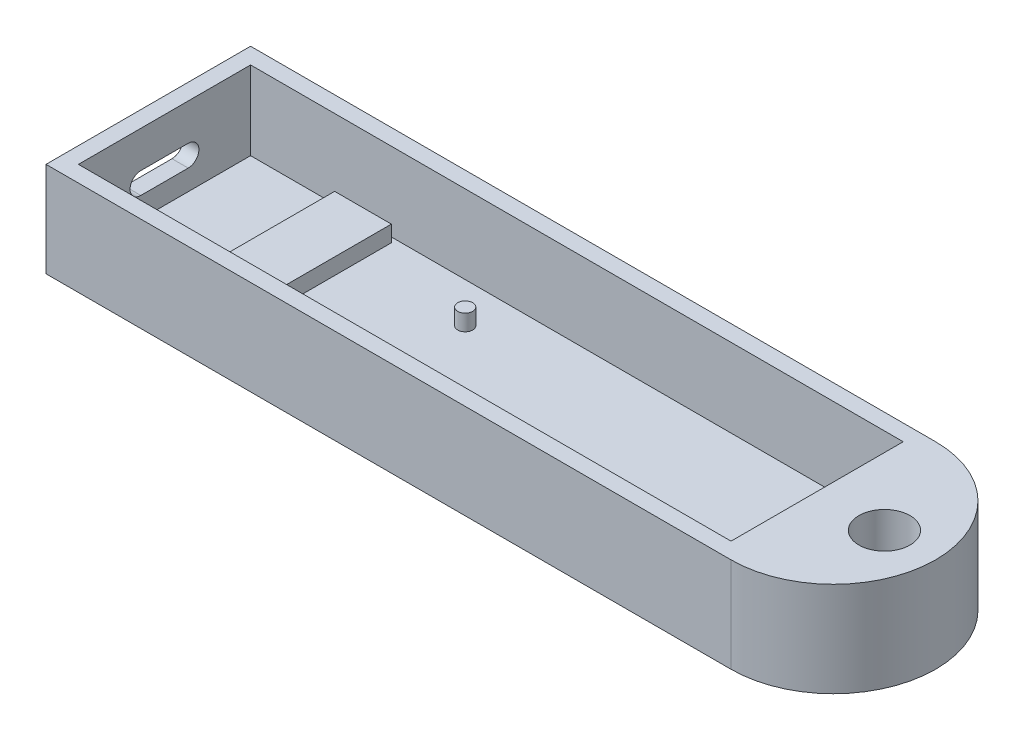
from build123d import *

# Parameters (mm, degrees)
SKETCH1_W           = 7
SKETCH1_H           = 20
BOSS_EXTRUDE2_DEPTH = 4
SKETCH1_4_R         = 0.925
SKETCH1_4_W         = 7
SKETCH1_4_H         = 20
BOSS_EXTRUDE3_DEPTH = 2
SKETCH1_5_R         = 0.925
BOSS_EXTRUDE4_DEPTH = 4
SKETCH1_6_R         = 3.155
BOSS_EXTRUDE5_DEPTH = 11.7
CUT_EXTRUDE1_DEPTH  = 4.85


with BuildPart() as part:
    # Sketch1 → Boss-Extrude2 (new body)
    with BuildSketch(Plane(origin=(0, 0, 0), x_dir=(1, 0, 0), z_dir=(0, 1, 0))):
        with Locations((-33.759922188, -0.124838084)):
            Rectangle(SKETCH1_W, SKETCH1_H)
    extrude(amount=BOSS_EXTRUDE2_DEPTH)

    # Sketch1_4 → Boss-Extrude3 (add)
    with BuildSketch(Plane(origin=(0, 0, 0), x_dir=(1, 0, 0), z_dir=(0, 1, 0))):
        with BuildLine():
            ThreePointArc((27.470986964, -10.749838084), (21.665077812, -0.124838084), (27.470986964, 10.500161916))
            Line((27.470986964, 10.500161916), (-48.259922188, 10.500161916))
            Line((-48.259922188, 10.500161916), (-48.259922188, -10.749838084))
            Line((-48.259922188, -10.749838084), (27.470986964, -10.749838084))
        make_face()
        with Locations((-16.839922188, -7.381359305)):
            Circle(SKETCH1_4_R, mode=Mode.SUBTRACT)
        with Locations((-33.759922188, -0.124838084)):
            Rectangle(SKETCH1_4_W, SKETCH1_4_H, mode=Mode.SUBTRACT)
        with Locations((-16.839922188, 5.570161916)):
            Circle(SKETCH1_4_R, mode=Mode.SUBTRACT)
        with BuildLine():
            Line((32.290077812, 10.500161916), (27.470986964, 10.500161916))
            ThreePointArc((27.470986964, 10.500161916), (21.665077812, -0.124838084), (27.470986964, -10.749838084))
            Line((27.470986964, -10.749838084), (32.290077812, -10.749838084))
            Line((32.290077812, -10.749838084), (32.290077812, 10.500161916))
        make_face()
        with Locations((30.160077812, -7.381359305)):
            Circle(SKETCH1_4_R, mode=Mode.SUBTRACT)
        with Locations((30.160077812, 5.570161916)):
            Circle(SKETCH1_4_R, mode=Mode.SUBTRACT)
    extrude(amount=BOSS_EXTRUDE3_DEPTH)

    # Sketch1_5 → Boss-Extrude4 (add)
    with BuildSketch(Plane(origin=(0, 0, 0), x_dir=(1, 0, 0), z_dir=(0, 1, 0))):
        with Locations((-16.839922188, 5.570161916)):
            Circle(SKETCH1_5_R)
        with Locations((-16.839922188, -7.381359305)):
            Circle(SKETCH1_5_R)
        with Locations((30.160077812, -7.381359305)):
            Circle(SKETCH1_5_R)
        with Locations((30.160077812, 5.570161916)):
            Circle(SKETCH1_5_R)
    extrude(amount=BOSS_EXTRUDE4_DEPTH)

    # Sketch1_6 → Boss-Extrude5 (add)
    with BuildSketch(Plane(origin=(0, 0, 0), x_dir=(1, 0, 0), z_dir=(0, 1, 0))):
        with BuildLine():
            Line((34.290077812, 12.500161916), (-50.259922188, 12.500161916))
            Line((-50.259922188, 12.500161916), (-50.259922188, -12.749838084))
            Line((-50.259922188, -12.749838084), (34.290077812, -12.749838084))
            ThreePointArc((34.290077812, -12.749838084), (30.736910211, -12.239524419), (27.470986964, -10.749838084))
            Line((27.470986964, -10.749838084), (-48.259922188, -10.749838084))
            Line((-48.259922188, -10.749838084), (-48.259922188, 10.500161916))
            Line((-48.259922188, 10.500161916), (27.470986964, 10.500161916))
            ThreePointArc((27.470986964, 10.500161916), (30.736910211, 11.989848251), (34.290077812, 12.500161916))
        make_face()
        with BuildLine():
            Line((34.290077812, -12.749838084), (34.290077812, 12.500161916))
            ThreePointArc((34.290077812, 12.500161916), (30.736910211, 11.989848251), (27.470986964, 10.500161916))
            Line((27.470986964, 10.500161916), (32.290077812, 10.500161916))
            Line((32.290077812, 10.500161916), (32.290077812, -10.749838084))
            Line((32.290077812, -10.749838084), (27.470986964, -10.749838084))
            ThreePointArc((27.470986964, -10.749838084), (30.736910211, -12.239524419), (34.290077812, -12.749838084))
        make_face()
        with BuildLine():
            ThreePointArc((46.915077812, -0.124838084), (43.217300925, 8.802385028), (34.290077812, 12.500161916))
            Line((34.290077812, 12.500161916), (34.290077812, -12.749838084))
            ThreePointArc((34.290077812, -12.749838084), (43.217300925, -9.052061197), (46.915077812, -0.124838084))
        make_face()
        with Locations((40.600077812, -0.124838084)):
            Circle(SKETCH1_6_R, mode=Mode.SUBTRACT)
    extrude(amount=BOSS_EXTRUDE5_DEPTH)

    # Sketch3 → Cut-Extrude1 (cut, symmetric)
    with BuildSketch(Plane.ZY.offset(50.259922188)):
        with BuildLine():
            Line((-2.800161916, 7.175), (3.049838084, 7.175))
            ThreePointArc((3.049838084, 7.175), (4.374838084, 5.85), (3.049838084, 4.525))
            Line((3.049838084, 4.525), (-2.800161916, 4.525))
            ThreePointArc((-2.800161916, 4.525), (-4.125161916, 5.85), (-2.800161916, 7.175))
        make_face()
    extrude(amount=CUT_EXTRUDE1_DEPTH, both=True, mode=Mode.SUBTRACT)


solid = part.part
